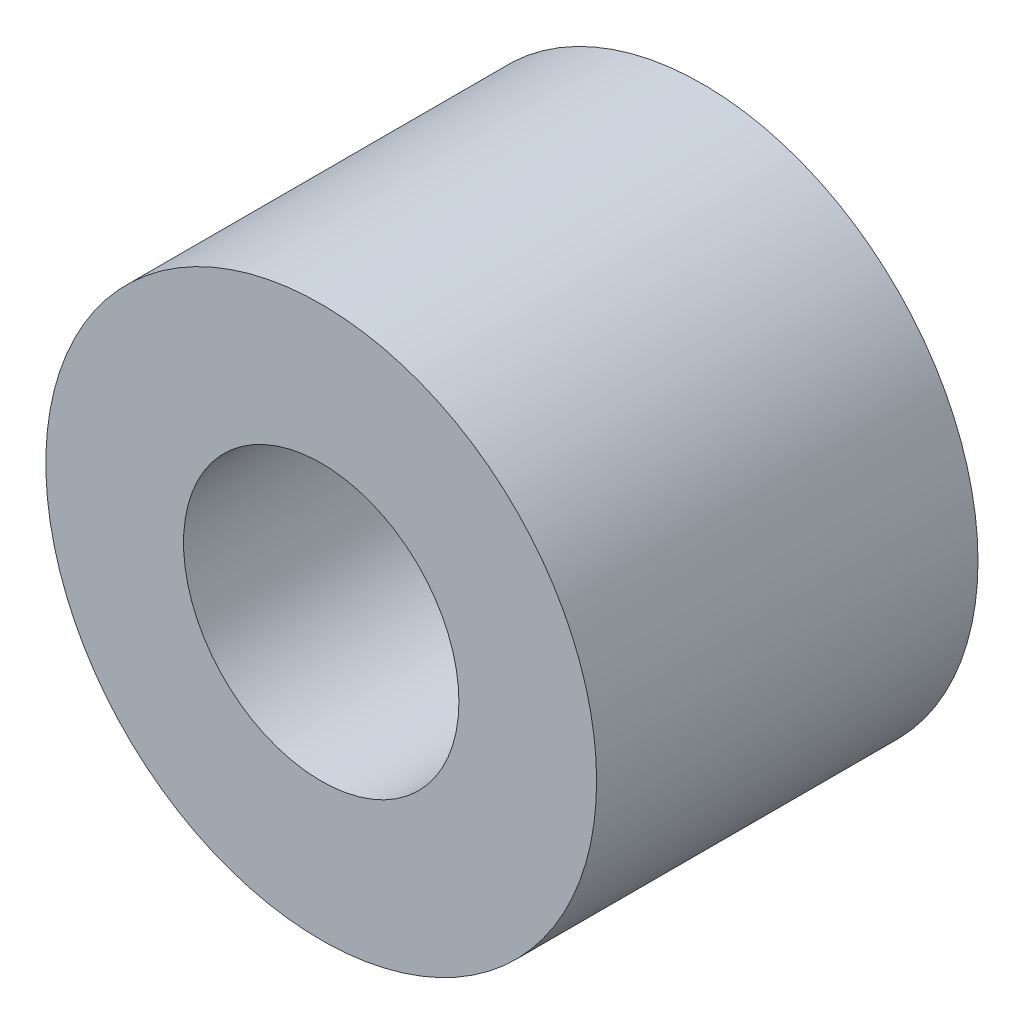
from build123d import *

# Parameters (mm, degrees)
SKETCH1_R           = 6.35
SKETCH1_R_2         = 3.175
BOSS_EXTRUDE1_DEPTH = 8.793740604


with BuildPart() as part:
    # Sketch1 → Boss-Extrude1 (new body)
    with BuildSketch(Plane.XY):
        Circle(SKETCH1_R)
        Circle(SKETCH1_R_2, mode=Mode.SUBTRACT)
    extrude(amount=BOSS_EXTRUDE1_DEPTH)


solid = part.part
